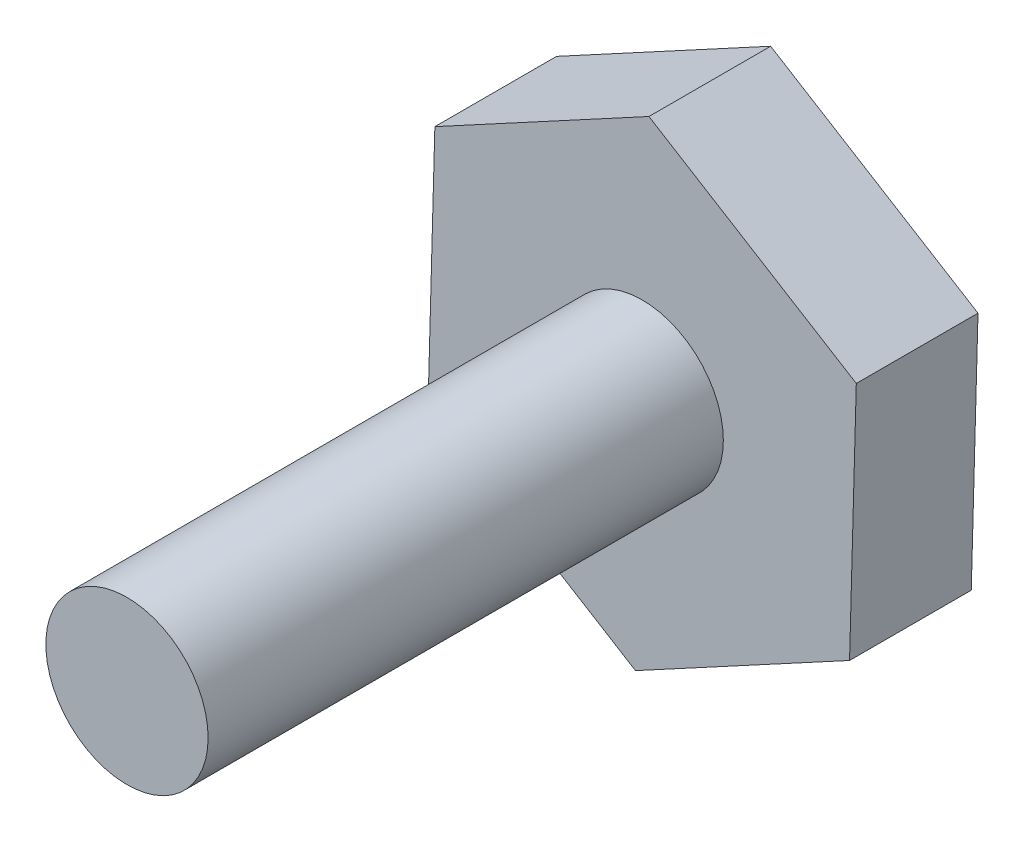
from build123d import *

# Parameters (mm, degrees)
BOSS_EXTRUDE1_DEPTH = 3
SKETCH2_R           = 2
BOSS_EXTRUDE2_DEPTH = 12.7


with BuildPart() as part:
    # Sketch1 → Boss-Extrude1 (new body)
    with BuildSketch(Plane.XY):
        Polygon((5.277260677, 2.854911514), (0.166204442, 5.997697565), (-5.111056235, 3.142786052), (-5.277260677, -2.854911514), (-0.166204442, -5.997697565), (5.111056235, -3.142786052), align=None)
    extrude(amount=BOSS_EXTRUDE1_DEPTH)

    # Sketch2 → Boss-Extrude2 (add)
    with BuildSketch(Plane.XY.offset(3)):
        Circle(SKETCH2_R)
    extrude(amount=BOSS_EXTRUDE2_DEPTH)


solid = part.part
